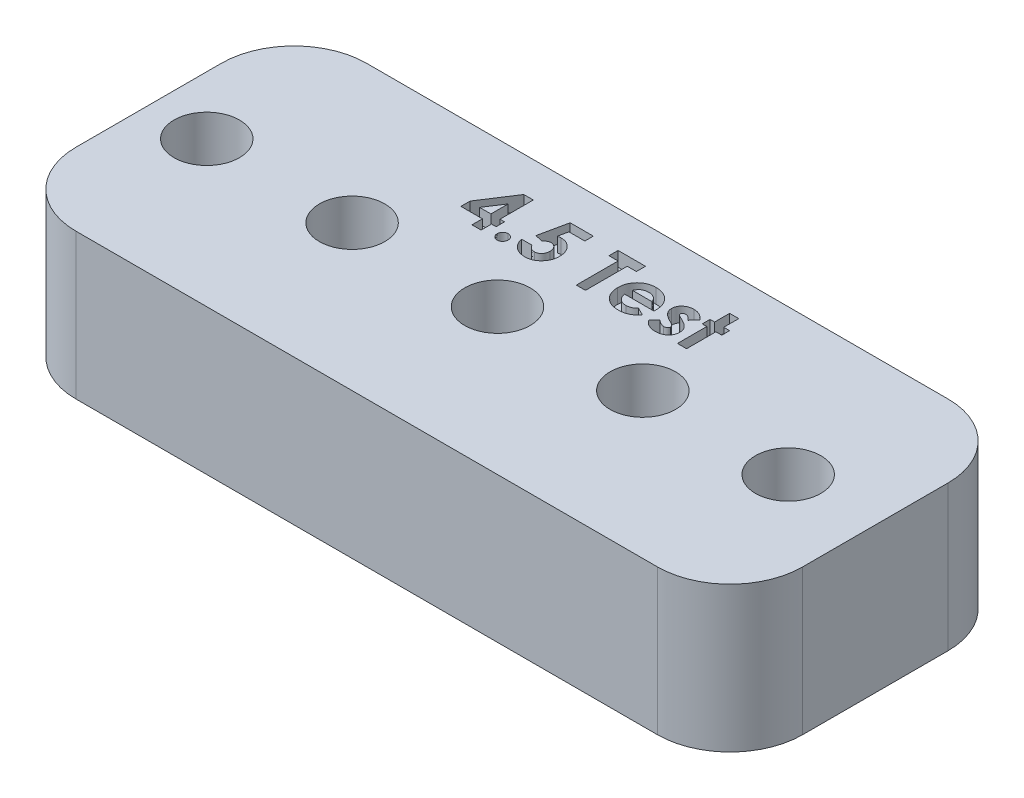
from build123d import *

# Parameters (mm, degrees)
SKETCH1_W                      = 100
SKETCH1_H                      = 20
BOSS_EXTRUDE1_DEPTH            = 10
M4_CLEARANCE_HOLE1_D           = 4.5
M4_CLEARANCE_HOLE1_DEPTH       = 5
M4_CLEARANCE_HOLE1_TIP         = 1.351936393
M4_CLEARANCE_HOLE2_D           = 4.5
M4_CLEARANCE_HOLE2_DEPTH       = 5
M4_CLEARANCE_HOLE2_TIP         = 1.351936393
CUT_EXTRUDE1_DEPTH             = 1
M4_CLEARANCE_HOLE3_D           = 4.5
M4_CLEARANCE_HOLE3_DEPTH       = 5
M4_CLEARANCE_HOLE3_TIP         = 1.351936393
F_5_0_5_DIAMETER_HOLE1_D       = 5
F_5_0_5_DIAMETER_HOLE1_DEPTH   = 5
F_5_0_5_DIAMETER_HOLE1_TIP     = 1.502151548
F_5_1_5_1_DIAMETER_HOLE1_D     = 5.1
F_5_1_5_1_DIAMETER_HOLE1_DEPTH = 5
F_5_1_5_1_DIAMETER_HOLE1_TIP   = 1.532194579
F_5_2_5_2_DIAMETER_HOLE1_D     = 5.2
F_5_2_5_2_DIAMETER_HOLE1_DEPTH = 5
F_5_2_5_2_DIAMETER_HOLE1_TIP   = 1.562237609
CUT_EXTRUDE2_DEPTH             = 1
FILLET1_R                      = 5
SKETCH33_W                     = 50
SKETCH33_H                     = 21.030948993
CUT_EXTRUDE4_DEPTH             = 52.961524362
FILLET2_R                      = 5


with BuildPart() as part:
    # Sketch1 → Boss-Extrude1 (new body)
    with BuildSketch(Plane(origin=(0, 0, 0), x_dir=(1, 0, 0), z_dir=(0, 1, 0))):
        Rectangle(SKETCH1_W, SKETCH1_H)
    extrude(amount=BOSS_EXTRUDE1_DEPTH)

    # M4 Clearance Hole1
    with Locations(Plane(origin=(0, 10, 0), x_dir=(1, 0, 0), z_dir=(0, 1, 0))):
        with Locations((-6, 0), (-16, 0)):
            Hole(M4_CLEARANCE_HOLE1_D / 2, depth=M4_CLEARANCE_HOLE1_DEPTH)
            with Locations((0, 0, -(M4_CLEARANCE_HOLE1_DEPTH + M4_CLEARANCE_HOLE1_TIP / 2))):  # 118° drill point
                Cone(0, M4_CLEARANCE_HOLE1_D / 2, M4_CLEARANCE_HOLE1_TIP, mode=Mode.SUBTRACT)

    # M4 Clearance Hole2
    with Locations(Plane(origin=(0, 10, 0), x_dir=(1, 0, 0), z_dir=(0, 1, 0))):
        with Locations((-26, 0), (-36, 0)):
            Hole(M4_CLEARANCE_HOLE2_D / 2, depth=M4_CLEARANCE_HOLE2_DEPTH)
            with Locations((0, 0, -(M4_CLEARANCE_HOLE2_DEPTH + M4_CLEARANCE_HOLE2_TIP / 2))):  # 118° drill point
                Cone(0, M4_CLEARANCE_HOLE2_D / 2, M4_CLEARANCE_HOLE2_TIP, mode=Mode.SUBTRACT)

    # Sketch9 → Cut-Extrude1 (cut)
    with BuildSketch(Plane(origin=(0, 10, 0), x_dir=(1, 0, 0), z_dir=(0, 1, 0))):
        Polygon((-31.779847756, 7.58974359), (-31.125, 7.58974359), (-31.125, 5.301282051), (-30.810897436, 5.301282051), (-30.810897436, 4.717948718), (-31.125, 4.717948718), (-31.125, 4), (-31.753205128, 4), (-31.753205128, 4.717948718), (-33.233974359, 4.717948718), (-33.233974359, 5.353866186), align=None)
        Polygon((-31.753205128, 5.301282051), (-31.753205128, 6.492487981), (-32.527944712, 5.301282051), align=None, mode=Mode.SUBTRACT)
        with BuildLine():
            add(Edge.make_bspline(
                [(-29.980769231, 4.717948718), (-29.955409335, 4.716558296), (-29.905480079, 4.713820795), (-29.833339112, 4.69339111), (-29.768231474, 4.656686271), (-29.710016547, 4.608811171), (-29.66079147, 4.551211032), (-29.625212697, 4.485525117), (-29.603056903, 4.41366212), (-29.600610888, 4.36357578), (-29.599358974, 4.337940705)],
                knots=[0, 0, 0, 0, 1.016957001, 2.002212695, 2.9757545, 3.99499976, 5.013036768, 5.994806404, 6.97370641, 8, 8, 8, 8], degree=3))
            add(Edge.make_bspline(
                [(-29.599358974, 4.337940705), (-29.600602687, 4.312301513), (-29.603032678, 4.262207129), (-29.625366013, 4.190204101), (-29.660738304, 4.123978308), (-29.710020496, 4.065760947), (-29.767990386, 4.016983595), (-29.833488806, 3.980617228), (-29.905342652, 3.95902862), (-29.955385146, 3.956440852), (-29.980769231, 3.955128205)],
                knots=[0, 0, 0, 0, 1.023218912, 1.999186227, 2.986238111, 4.008388923, 5.030539734, 6.0011649, 6.986089706, 8, 8, 8, 8], degree=3))
            add(Edge.make_bspline(
                [(-29.980769231, 3.955128205), (-30.00615933, 3.956430178), (-30.056213682, 3.958996903), (-30.12817922, 3.980799199), (-30.1941612, 4.016740799), (-30.252145655, 4.065820114), (-30.301648018, 4.123772156), (-30.336014642, 4.190413056), (-30.358556005, 4.262179983), (-30.360952777, 4.312292323), (-30.362179487, 4.337940705)],
                knots=[0, 0, 0, 0, 1.013427518, 1.99788335, 2.976245624, 3.997909735, 5.019573847, 6.001765691, 6.977268297, 8, 8, 8, 8], degree=3))
            add(Edge.make_bspline(
                [(-30.362179487, 4.337940705), (-30.360944684, 4.363585131), (-30.3585321, 4.413689738), (-30.336167521, 4.485313756), (-30.30159294, 4.551418305), (-30.252149783, 4.608751881), (-30.19391887, 4.656927172), (-30.128329753, 4.693211633), (-30.056076324, 4.713852746), (-30.00613517, 4.716569058), (-29.980769231, 4.717948718)],
                knots=[0, 0, 0, 0, 1.025808215, 2.00424526, 2.981110158, 3.998665696, 5.017428914, 5.998734231, 6.983523959, 8, 8, 8, 8], degree=3))
        make_face()
        with BuildLine():
            Line((-28.500701122, 7.5), (-26.907051282, 7.5))
            Line((-26.907051282, 7.5), (-26.907051282, 6.916666667))
            Line((-26.907051282, 6.916666667), (-28.002904647, 6.916666667))
            Line((-28.002904647, 6.916666667), (-28.139623397, 6.254807692))
            add(Edge.make_bspline(
                [(-28.139623397, 6.254807692), (-28.120993511, 6.259996351), (-28.084251546, 6.270229452), (-28.028899731, 6.280491957), (-27.975256109, 6.287143787), (-27.940055491, 6.288031053), (-27.922976763, 6.288461538)],
                knots=[0, 0, 0, 0, 1.05461699, 2.079921384, 3.068411212, 4, 4, 4, 4], degree=3))
            add(Edge.make_bspline(
                [(-27.922976763, 6.288461538), (-27.885760425, 6.287608748), (-27.812398825, 6.285927709), (-27.705080113, 6.26996917), (-27.602316106, 6.244834954), (-27.504421274, 6.208988378), (-27.411491247, 6.162333132), (-27.323413376, 6.105893363), (-27.240079559, 6.039569942), (-27.162970155, 5.963321345), (-27.092118815, 5.879598659), (-27.030517615, 5.789043716), (-26.977906346, 5.69294774), (-26.936061162, 5.590713401), (-26.903033375, 5.4829828), (-26.879166759, 5.3696869), (-26.865053236, 5.250691427), (-26.863150114, 5.169509324), (-26.862179487, 5.128104968)],
                knots=[0, 0, 0, 0, 1.01440847, 1.999622559, 2.951875003, 3.895578053, 4.836219714, 5.782137149, 6.743708247, 7.735272588, 8.734977101, 9.730283169, 10.717124674, 11.717316708, 12.737475749, 13.78628267, 14.87096371, 16, 16, 16, 16], degree=3))
            add(Edge.make_bspline(
                [(-26.862179487, 5.128104968), (-26.863365609, 5.086230577), (-26.865706174, 5.003600162), (-26.880976216, 4.882104224), (-26.907928114, 4.765738544), (-26.944949243, 4.654191613), (-26.99372221, 4.548283274), (-27.052378378, 4.446916397), (-27.121909465, 4.350843395), (-27.201633132, 4.261049133), (-27.288303217, 4.178975454), (-27.380586397, 4.106775081), (-27.477834357, 4.046019052), (-27.580049442, 3.996917909), (-27.686645213, 3.958069959), (-27.797654022, 3.929790505), (-27.913615358, 3.91357381), (-27.992338037, 3.911374362), (-28.032351763, 3.91025641)],
                knots=[0, 0, 0, 0, 1.06808661, 2.107647099, 3.116961351, 4.110378221, 5.100014249, 6.085620622, 7.093190682, 8.119403071, 9.144090782, 10.133780668, 11.103064255, 12.062861538, 13.020824475, 13.992378307, 14.979551724, 16, 16, 16, 16], degree=3))
            add(Edge.make_bspline(
                [(-28.032351763, 3.91025641), (-28.068134846, 3.911170964), (-28.138706575, 3.912974655), (-28.242655634, 3.924061093), (-28.34287407, 3.943662018), (-28.438829833, 3.972029632), (-28.531532538, 4.006943689), (-28.619910514, 4.050610316), (-28.704449415, 4.10219804), (-28.784909182, 4.160765386), (-28.859982458, 4.226739229), (-28.928501389, 4.298958967), (-28.990880798, 4.376514305), (-29.045785863, 4.460362042), (-29.093044473, 4.550378295), (-29.134954373, 4.645502204), (-29.169258045, 4.746727166), (-29.186666171, 4.816901933), (-29.195512821, 4.852564103)],
                knots=[0, 0, 0, 0, 1.054957082, 2.080596141, 3.077793124, 4.061112343, 5.027190972, 5.994718051, 6.962465889, 7.943658696, 8.924948258, 9.904494768, 10.875059, 11.855380583, 12.854004648, 13.869083016, 14.917087635, 16, 16, 16, 16], degree=3))
            Line((-29.195512821, 4.852564103), (-28.477564103, 4.852564103))
            add(Edge.make_bspline(
                [(-28.477564103, 4.852564103), (-28.464439983, 4.827851671), (-28.438934753, 4.779825881), (-28.390418169, 4.716064428), (-28.336106932, 4.661691401), (-28.276490961, 4.616175562), (-28.21118398, 4.58207587), (-28.142847127, 4.556216242), (-28.070621913, 4.54127292), (-28.021433353, 4.539404857), (-27.996594551, 4.538461538)],
                knots=[0, 0, 0, 0, 1.104910296, 2.147267069, 3.153527244, 4.136738762, 5.099945312, 6.05603338, 7.018353, 8, 8, 8, 8], degree=3))
            add(Edge.make_bspline(
                [(-27.996594551, 4.538461538), (-27.97928224, 4.539112908), (-27.945219975, 4.540394488), (-27.895034613, 4.547174369), (-27.847130481, 4.560015309), (-27.801151422, 4.577797026), (-27.756973925, 4.599972835), (-27.71523129, 4.62796835), (-27.67519727, 4.660192225), (-27.637481345, 4.697169231), (-27.603321587, 4.738389992), (-27.573367217, 4.782684509), (-27.546583879, 4.829068549), (-27.526745051, 4.879379501), (-27.510498729, 4.932115061), (-27.49853428, 4.98767303), (-27.491384172, 5.046118294), (-27.490722263, 5.086017238), (-27.490384615, 5.106370192)],
                knots=[0, 0, 0, 0, 0.978869489, 1.925942215, 2.855067702, 3.774946051, 4.70828698, 5.642468714, 6.60995405, 7.609372294, 8.622401667, 9.629904756, 10.629323, 11.642352373, 12.678539694, 13.745912462, 14.850161547, 16, 16, 16, 16], degree=3))
            add(Edge.make_bspline(
                [(-27.490384615, 5.106370192), (-27.490776495, 5.126250708), (-27.491539298, 5.164948615), (-27.497849357, 5.221771003), (-27.50913793, 5.275685166), (-27.524518709, 5.327104046), (-27.544207941, 5.375715402), (-27.5682695, 5.421808594), (-27.596806177, 5.465150636), (-27.629971182, 5.504859127), (-27.665338001, 5.541280884), (-27.703333329, 5.573135063), (-27.743614849, 5.59957182), (-27.784930861, 5.622651878), (-27.828930552, 5.639449041), (-27.874624547, 5.651016627), (-27.921964791, 5.659504457), (-27.954254544, 5.660003148), (-27.970653045, 5.66025641)],
                knots=[0, 0, 0, 0, 1.166249705, 2.270133367, 3.348514167, 4.393962215, 5.415026464, 6.420877785, 7.440098956, 8.453121383, 9.451844239, 10.415694839, 11.355045125, 12.27538808, 13.187007209, 14.108269027, 15.039275622, 16, 16, 16, 16], degree=3))
            add(Edge.make_bspline(
                [(-27.970653045, 5.66025641), (-27.988465629, 5.659580522), (-28.024165868, 5.658225896), (-28.077207488, 5.647203668), (-28.129609573, 5.629365569), (-28.181663534, 5.604755084), (-28.232852644, 5.572547724), (-28.284527808, 5.534772184), (-28.33495935, 5.488683712), (-28.367025126, 5.454356913), (-28.383613782, 5.436598558)],
                knots=[0, 0, 0, 0, 0.88288272, 1.769486374, 2.674910571, 3.623812639, 4.617874466, 5.670434592, 6.794841017, 8, 8, 8, 8], degree=3))
            Line((-28.383613782, 5.436598558), (-28.912259615, 5.557892628))
            Line((-28.912259615, 5.557892628), (-28.500701122, 7.5))
        make_face()
        Polygon((-25.201923077, 7.5), (-23.317307692, 7.5), (-23.317307692, 6.871794872), (-23.945512821, 6.871794872), (-23.945512821, 4), (-24.573717949, 4), (-24.573717949, 6.871794872), (-25.201923077, 6.871794872), align=None)
        with BuildLine():
            Line((-20.357872596, 5.121794872), (-22.375, 5.121794872))
            add(Edge.make_bspline(
                [(-22.375, 5.121794872), (-22.37088724, 5.098356996), (-22.362805342, 5.05229972), (-22.345255214, 4.985397531), (-22.322858619, 4.922350037), (-22.296017709, 4.863072959), (-22.265185024, 4.807252923), (-22.22922125, 4.755151746), (-22.188582557, 4.706815448), (-22.143503905, 4.662454103), (-22.094736675, 4.622705377), (-22.042517369, 4.58788298), (-21.986792101, 4.559330745), (-21.928199739, 4.535264173), (-21.866302464, 4.51620101), (-21.801009178, 4.503053509), (-21.732492965, 4.495287233), (-21.685817627, 4.494163929), (-21.661959135, 4.493589744)],
                knots=[0, 0, 0, 0, 1.091296461, 2.144483647, 3.168565212, 4.157007626, 5.126487748, 6.090021542, 7.05641414, 8.019231907, 8.98705074, 9.938580405, 10.892824166, 11.854447369, 12.841318655, 13.858982407, 14.905600794, 16, 16, 16, 16], degree=3))
            add(Edge.make_bspline(
                [(-21.661959135, 4.493589744), (-21.633160314, 4.49435006), (-21.576446956, 4.495847348), (-21.493361464, 4.509126063), (-21.413005691, 4.52918298), (-21.336140084, 4.559009298), (-21.261874277, 4.596137822), (-21.191430914, 4.642395393), (-21.123590673, 4.696430216), (-21.082200132, 4.738080236), (-21.061097756, 4.759314904)],
                knots=[0, 0, 0, 0, 1.021034703, 2.010718019, 2.977989445, 3.954245119, 4.929443971, 5.918328161, 6.938689359, 8, 8, 8, 8], degree=3))
            Line((-21.061097756, 4.759314904), (-20.53525641, 4.509014423))
            add(Edge.make_bspline(
                [(-20.53525641, 4.509014423), (-20.551812218, 4.486136838), (-20.584616943, 4.440805743), (-20.638169554, 4.377013186), (-20.694055115, 4.317492141), (-20.752315303, 4.26263409), (-20.813024008, 4.212595354), (-20.876012353, 4.166766372), (-20.942200886, 4.126377634), (-21.010266179, 4.089475157), (-21.081615269, 4.057838835), (-21.156050701, 4.030860496), (-21.233257199, 4.006472307), (-21.314209714, 3.987889843), (-21.398234155, 3.973180116), (-21.485531526, 3.962734261), (-21.57609032, 3.956282357), (-21.637642605, 3.955517492), (-21.668970353, 3.955128205)],
                knots=[0, 0, 0, 0, 1.028154879, 2.037251081, 3.030720504, 4.000128189, 4.949298328, 5.894184978, 6.834267904, 7.770992897, 8.712077017, 9.673380525, 10.653304757, 11.658697181, 12.695551717, 13.758623199, 14.859225354, 16, 16, 16, 16], degree=3))
            add(Edge.make_bspline(
                [(-21.668970353, 3.955128205), (-21.717167577, 3.956110802), (-21.811559065, 3.95803516), (-21.949623678, 3.97589596), (-22.080746767, 4.005511093), (-22.205298578, 4.045768317), (-22.322740714, 4.098920464), (-22.433131298, 4.163929949), (-22.53757329, 4.23955041), (-22.632875404, 4.32736892), (-22.719698442, 4.422954147), (-22.7959584, 4.525606153), (-22.859771647, 4.634607748), (-22.912176369, 4.749237537), (-22.952907139, 4.869788926), (-22.982271662, 4.996314522), (-23.000272466, 5.128753894), (-23.002216642, 5.218959891), (-23.003205128, 5.264823718)],
                knots=[0, 0, 0, 0, 1.103565453, 2.161269334, 3.182010356, 4.179077853, 5.15417608, 6.128274628, 7.109042802, 8.101804412, 9.090965879, 10.063106201, 11.02526161, 11.978650795, 12.945248442, 13.93468508, 14.949922959, 16, 16, 16, 16], degree=3))
            add(Edge.make_bspline(
                [(-23.003205128, 5.264823718), (-23.002206913, 5.311853003), (-23.000242971, 5.404381011), (-22.982426648, 5.539878469), (-22.952825956, 5.669161371), (-22.911976039, 5.792407752), (-22.860366304, 5.910003076), (-22.795741143, 6.020918523), (-22.719736286, 6.125540241), (-22.633226026, 6.223378799), (-22.537520183, 6.311688786), (-22.435823682, 6.390390633), (-22.32699386, 6.455970236), (-22.212261675, 6.508958515), (-22.092360996, 6.552010153), (-21.965905939, 6.580657423), (-21.833858633, 6.59989235), (-21.743594002, 6.601663767), (-21.697716346, 6.602564103)],
                knots=[0, 0, 0, 0, 1.079208495, 2.12329425, 3.130605359, 4.119693003, 5.099659317, 6.073216462, 7.060498243, 8.06384408, 9.066070512, 10.045757761, 11.010926815, 11.975797609, 12.942977511, 13.929384301, 14.947594487, 16, 16, 16, 16], degree=3))
            add(Edge.make_bspline(
                [(-21.697716346, 6.602564103), (-21.649288224, 6.601566262), (-21.554204597, 6.599607105), (-21.415178406, 6.58189133), (-21.283184675, 6.552095608), (-21.157661038, 6.512186481), (-21.040210482, 6.457691654), (-20.928252262, 6.39428195), (-20.824471772, 6.317026895), (-20.727762823, 6.229638141), (-20.640463231, 6.132683347), (-20.564153715, 6.027360745), (-20.499223708, 5.914698223), (-20.446597294, 5.79423891), (-20.405908347, 5.666344436), (-20.376516642, 5.531180898), (-20.35865314, 5.388234198), (-20.356745141, 5.290350399), (-20.355769231, 5.240284455)],
                knots=[0, 0, 0, 0, 1.080001299, 2.120471247, 3.119684163, 4.095710327, 5.052285597, 6.002875087, 6.961153713, 7.931888285, 8.906493152, 9.865905668, 10.82813294, 11.801621613, 12.7925306, 13.817193356, 14.883530496, 16, 16, 16, 16], degree=3))
            Line((-20.355769231, 5.240284455), (-20.357872596, 5.121794872))
        make_face()
        with BuildLine():
            add(Edge.make_bspline(
                [(-20.983974359, 5.615384615), (-20.995828974, 5.647375419), (-21.019399037, 5.710981471), (-21.072642827, 5.798742302), (-21.143295634, 5.874746746), (-21.225469917, 5.942034083), (-21.319359181, 5.996648688), (-21.42200481, 6.036191437), (-21.532109384, 6.059901765), (-21.607855398, 6.06268257), (-21.646534455, 6.064102564)],
                knots=[0, 0, 0, 0, 0.954238005, 1.897273737, 2.851915805, 3.847685534, 4.862635127, 5.880135777, 6.917509367, 8, 8, 8, 8], degree=3))
            add(Edge.make_bspline(
                [(-21.646534455, 6.064102564), (-21.688778284, 6.062738487), (-21.771356172, 6.060071999), (-21.890469154, 6.031712926), (-22.002825449, 5.989387857), (-22.069064352, 5.945749811), (-22.102263622, 5.923878205)],
                knots=[0, 0, 0, 0, 1.044195649, 2.041185066, 3.018232172, 4, 4, 4, 4], degree=3))
            add(Edge.make_bspline(
                [(-22.102263622, 5.923878205), (-22.122977486, 5.907220311), (-22.167138387, 5.871706531), (-22.224490275, 5.800859913), (-22.280982362, 5.715080563), (-22.313101229, 5.649925086), (-22.330128205, 5.615384615)],
                knots=[0, 0, 0, 0, 0.82159062, 1.751589201, 2.808063854, 4, 4, 4, 4], degree=3))
            Line((-22.330128205, 5.615384615), (-20.983974359, 5.615384615))
        make_face(mode=Mode.SUBTRACT)
        with BuildLine():
            Line((-18.246794872, 6.162960737), (-18.631009615, 5.75))
            add(Edge.make_bspline(
                [(-18.631009615, 5.75), (-18.650195298, 5.771229998), (-18.686890242, 5.811834943), (-18.743066654, 5.867188557), (-18.798406489, 5.913281766), (-18.851878495, 5.952001983), (-18.90457476, 5.981695761), (-18.956057261, 6.003059769), (-19.006350697, 6.016621959), (-19.039687313, 6.018377533), (-19.055889423, 6.019230769)],
                knots=[0, 0, 0, 0, 1.327646587, 2.539285, 3.655602211, 4.666613517, 5.598770349, 6.454635452, 7.248928967, 8, 8, 8, 8], degree=3))
            add(Edge.make_bspline(
                [(-19.055889423, 6.019230769), (-19.072284331, 6.018731109), (-19.10367548, 6.017774414), (-19.147975424, 6.009568373), (-19.186895889, 5.995362204), (-19.219829496, 5.975997872), (-19.246288939, 5.952143003), (-19.264814428, 5.924853596), (-19.277254465, 5.894978416), (-19.278306812, 5.873756921), (-19.278846154, 5.862880609)],
                knots=[0, 0, 0, 0, 1.295068245, 2.479652818, 3.543291146, 4.55379989, 5.481948265, 6.332409746, 7.145336708, 8, 8, 8, 8], degree=3))
            add(Edge.make_bspline(
                [(-19.278846154, 5.862880609), (-19.277018813, 5.846398295), (-19.273227292, 5.812199408), (-19.247184803, 5.772533801), (-19.21272871, 5.743273295), (-19.173010797, 5.716044713), (-19.119222461, 5.685600244), (-19.078417263, 5.664754027), (-19.055889423, 5.653245192)],
                knots=[0, 0, 0, 0, 0.916701701, 1.902049539, 2.5493345, 3.440293453, 4.586830489, 6, 6, 6, 6], degree=3))
            Line((-19.055889423, 5.653245192), (-18.828725962, 5.538261218))
            add(Edge.make_bspline(
                [(-18.828725962, 5.538261218), (-18.799826426, 5.523586972), (-18.743755898, 5.49511618), (-18.664925988, 5.449174733), (-18.592117427, 5.404644983), (-18.526790732, 5.359008004), (-18.468546063, 5.313056663), (-18.417797129, 5.266336561), (-18.373313011, 5.220328815), (-18.323706976, 5.158645006), (-18.274086053, 5.076487191), (-18.232717615, 4.969644781), (-18.206337464, 4.855240051), (-18.203418804, 4.776056176), (-18.201923077, 4.735476763)],
                knots=[0, 0, 0, 0, 1.076693506, 2.088987655, 3.030641824, 3.911722491, 4.735175175, 5.493635918, 6.202154166, 6.859459289, 8.120623445, 9.372284821, 10.653373066, 12, 12, 12, 12], degree=3))
            add(Edge.make_bspline(
                [(-18.201923077, 4.735476763), (-18.202824262, 4.708100165), (-18.204588121, 4.654516899), (-18.215738866, 4.575647439), (-18.235768491, 4.50065426), (-18.262127446, 4.428368367), (-18.29763217, 4.360096911), (-18.340736644, 4.295508935), (-18.390760233, 4.233756435), (-18.449025382, 4.17695184), (-18.512853879, 4.124010581), (-18.583810025, 4.079483179), (-18.658756447, 4.040333359), (-18.739673112, 4.009760836), (-18.825424658, 3.984974642), (-18.916746152, 3.967798431), (-19.013327723, 3.956989001), (-19.079463864, 3.955759003), (-19.11338141, 3.955128205)],
                knots=[0, 0, 0, 0, 0.976600749, 1.911466839, 2.833459288, 3.740827163, 4.650527853, 5.570709661, 6.506801416, 7.479409329, 8.468875524, 9.458587492, 10.461481786, 11.480119772, 12.538142914, 13.641687514, 14.790552763, 16, 16, 16, 16], degree=3))
            add(Edge.make_bspline(
                [(-19.11338141, 3.955128205), (-19.158319246, 3.956559226), (-19.246528262, 3.959368193), (-19.375351143, 3.978935056), (-19.496994143, 4.012805626), (-19.61155734, 4.060253962), (-19.719742417, 4.120716149), (-19.820004371, 4.195736488), (-19.914081334, 4.283360382), (-19.968816289, 4.350563828), (-19.996794872, 4.384915865)],
                knots=[0, 0, 0, 0, 1.056901255, 2.07460411, 3.05625841, 4.019970729, 4.984811261, 5.963335951, 6.958928997, 8, 8, 8, 8], degree=3))
            Line((-19.996794872, 4.384915865), (-19.616085737, 4.807692308))
            add(Edge.make_bspline(
                [(-19.616085737, 4.807692308), (-19.597536302, 4.788127424), (-19.560709608, 4.749284732), (-19.498634683, 4.69806539), (-19.432955015, 4.651382728), (-19.362939434, 4.612184524), (-19.292909706, 4.580533738), (-19.225721959, 4.556791221), (-19.162642422, 4.541870652), (-19.121629733, 4.539558825), (-19.102163462, 4.538461538)],
                knots=[0, 0, 0, 0, 1.087861918, 2.159761696, 3.243809206, 4.338405912, 5.394481878, 6.343674753, 7.213841449, 8, 8, 8, 8], degree=3))
            add(Edge.make_bspline(
                [(-19.102163462, 4.538461538), (-19.082707727, 4.53902499), (-19.045308437, 4.540108098), (-18.992154361, 4.551374552), (-18.945041454, 4.570315126), (-18.905087954, 4.596576712), (-18.871855703, 4.626721002), (-18.848439953, 4.660980164), (-18.832956219, 4.697307916), (-18.831074353, 4.722706898), (-18.830128205, 4.735476763)],
                knots=[0, 0, 0, 0, 1.255011871, 2.412479185, 3.488767498, 4.514443302, 5.48617286, 6.365347346, 7.178144445, 8, 8, 8, 8], degree=3))
            add(Edge.make_bspline(
                [(-18.830128205, 4.735476763), (-18.830972449, 4.747502279), (-18.832705845, 4.772192983), (-18.846429196, 4.808638228), (-18.867975127, 4.844724868), (-18.897858158, 4.880554648), (-18.936475921, 4.915836852), (-18.983690212, 4.950288881), (-19.038411796, 4.985748793), (-19.078832272, 5.006913612), (-19.100060096, 5.018028846)],
                knots=[0, 0, 0, 0, 0.704666567, 1.446816302, 2.258757648, 3.165368109, 4.175243826, 5.322435858, 6.59381024, 8, 8, 8, 8], degree=3))
            Line((-19.100060096, 5.018028846), (-19.308293269, 5.123197115))
            add(Edge.make_bspline(
                [(-19.308293269, 5.123197115), (-19.355528865, 5.148526732), (-19.4462035, 5.197150098), (-19.56876171, 5.280528839), (-19.672489541, 5.369287167), (-19.757471524, 5.462948244), (-19.825185336, 5.561249233), (-19.872420263, 5.665441698), (-19.902135347, 5.774537872), (-19.905404482, 5.84913902), (-19.907051282, 5.88671875)],
                knots=[0, 0, 0, 0, 1.255999728, 2.41104856, 3.467751088, 4.449286722, 5.368722015, 6.253902015, 7.120417131, 8, 8, 8, 8], degree=3))
            add(Edge.make_bspline(
                [(-19.907051282, 5.88671875), (-19.906480185, 5.911074399), (-19.90535903, 5.958888495), (-19.893423656, 6.029106809), (-19.875391867, 6.096604459), (-19.84994707, 6.161488639), (-19.81735273, 6.223823729), (-19.777419008, 6.283333092), (-19.729658718, 6.33990854), (-19.675600866, 6.393367831), (-19.615621983, 6.442055509), (-19.551435757, 6.485204177), (-19.483232038, 6.521958818), (-19.410451088, 6.551262233), (-19.334017992, 6.574585927), (-19.253428211, 6.590439711), (-19.169025577, 6.600522773), (-19.111307636, 6.601874018), (-19.081830929, 6.602564103)],
                knots=[0, 0, 0, 0, 0.959035663, 1.882742823, 2.798841253, 3.708806893, 4.623422363, 5.566085165, 6.527241613, 7.536786942, 8.55815439, 9.567237405, 10.580975912, 11.605536372, 12.654523293, 13.725718749, 14.838518481, 16, 16, 16, 16], degree=3))
            add(Edge.make_bspline(
                [(-19.081830929, 6.602564103), (-19.041079192, 6.601222387), (-18.960194181, 6.598559319), (-18.840904699, 6.577009755), (-18.725683432, 6.540789912), (-18.614853401, 6.490885025), (-18.509840224, 6.428168766), (-18.412953194, 6.352010045), (-18.323536612, 6.264284235), (-18.272629472, 6.197070624), (-18.246794872, 6.162960737)],
                knots=[0, 0, 0, 0, 0.996590028, 1.978055413, 2.954661574, 3.945146934, 4.945404762, 5.939399542, 6.954276554, 8, 8, 8, 8], degree=3))
        make_face()
        Polygon((-17.618589744, 7.58974359), (-16.990384615, 7.58974359), (-16.990384615, 6.557692308), (-16.586538462, 6.557692308), (-16.586538462, 6.019230769), (-16.990384615, 6.019230769), (-16.990384615, 4), (-17.618589744, 4), (-17.618589744, 6.019230769), (-17.932692308, 6.019230769), (-17.932692308, 6.557692308), (-17.618589744, 6.557692308), align=None)
    extrude(amount=-CUT_EXTRUDE1_DEPTH, mode=Mode.SUBTRACT)

    # M4 Clearance Hole3
    with Locations(Plane(origin=(0, 10, 0), x_dir=(1, 0, 0), z_dir=(0, 1, 0))):
        with Locations((-46, 0)):
            Hole(M4_CLEARANCE_HOLE3_D / 2, depth=M4_CLEARANCE_HOLE3_DEPTH)
            with Locations((0, 0, -(M4_CLEARANCE_HOLE3_DEPTH + M4_CLEARANCE_HOLE3_TIP / 2))):  # 118° drill point
                Cone(0, M4_CLEARANCE_HOLE3_D / 2, M4_CLEARANCE_HOLE3_TIP, mode=Mode.SUBTRACT)

    # Ø5.0 (5) Diameter Hole1
    with Locations(Plane(origin=(0, 10, 0), x_dir=(1, 0, 0), z_dir=(0, 1, 0))):
        with Locations((6, 0), (16, 0)):
            Hole(F_5_0_5_DIAMETER_HOLE1_D / 2, depth=F_5_0_5_DIAMETER_HOLE1_DEPTH)
            with Locations((0, 0, -(F_5_0_5_DIAMETER_HOLE1_DEPTH + F_5_0_5_DIAMETER_HOLE1_TIP / 2))):  # 118° drill point
                Cone(0, F_5_0_5_DIAMETER_HOLE1_D / 2, F_5_0_5_DIAMETER_HOLE1_TIP, mode=Mode.SUBTRACT)

    # Ø5.1 (5.1) Diameter Hole1
    with Locations(Plane(origin=(0, 10, 0), x_dir=(1, 0, 0), z_dir=(0, 1, 0))):
        with Locations((26, 0), (36, 0)):
            Hole(F_5_1_5_1_DIAMETER_HOLE1_D / 2, depth=F_5_1_5_1_DIAMETER_HOLE1_DEPTH)
            with Locations((0, 0, -(F_5_1_5_1_DIAMETER_HOLE1_DEPTH + F_5_1_5_1_DIAMETER_HOLE1_TIP / 2))):  # 118° drill point
                Cone(0, F_5_1_5_1_DIAMETER_HOLE1_D / 2, F_5_1_5_1_DIAMETER_HOLE1_TIP, mode=Mode.SUBTRACT)

    # Ø5.2 (5.2) Diameter Hole1
    with Locations(Plane(origin=(0, 10, 0), x_dir=(1, 0, 0), z_dir=(0, 1, 0))):
        with Locations((46, 0)):
            Hole(F_5_2_5_2_DIAMETER_HOLE1_D / 2, depth=F_5_2_5_2_DIAMETER_HOLE1_DEPTH)
            with Locations((0, 0, -(F_5_2_5_2_DIAMETER_HOLE1_DEPTH + F_5_2_5_2_DIAMETER_HOLE1_TIP / 2))):  # 118° drill point
                Cone(0, F_5_2_5_2_DIAMETER_HOLE1_D / 2, F_5_2_5_2_DIAMETER_HOLE1_TIP, mode=Mode.SUBTRACT)

    # Sketch24 → Cut-Extrude2 (cut)
    with BuildSketch(Plane(origin=(0, 10, 0), x_dir=(1, 0, 0), z_dir=(0, 1, 0))):
        Polygon((15.651943109, 7.5), (16.303986378, 7.5), (17.102564103, 5.05869391), (17.906750801, 7.5), (18.552483974, 7.5), (19.144230769, 4), (18.508313301, 4), (18.134615385, 6.210637019), (17.406850962, 4), (16.794070513, 4), (16.070512821, 6.210637019), (15.697516026, 4), (15.060897436, 4), align=None)
        with BuildLine():
            Line((20.266025641, 6.647435897), (19.637820513, 6.647435897))
            add(Edge.make_bspline(
                [(19.637820513, 6.647435897), (19.64225588, 6.678837631), (19.650951123, 6.740398649), (19.671757678, 6.829523667), (19.696644563, 6.914064846), (19.727714567, 6.993754462), (19.764154627, 7.068734468), (19.805594188, 7.139262159), (19.852481228, 7.205034816), (19.88842064, 7.244656526), (19.90635016, 7.264423077)],
                knots=[0, 0, 0, 0, 1.111473889, 2.178970933, 3.205615836, 4.199322666, 5.174200091, 6.12565194, 7.064921805, 8, 8, 8, 8], degree=3))
            add(Edge.make_bspline(
                [(19.90635016, 7.264423077), (19.932211117, 7.290503609), (19.983180345, 7.341905597), (20.068355903, 7.407745865), (20.157635618, 7.46472614), (20.252810034, 7.509900514), (20.352398164, 7.546463936), (20.457191969, 7.571023669), (20.566763222, 7.587319269), (20.641531818, 7.588924443), (20.6796875, 7.58974359)],
                knots=[0, 0, 0, 0, 1.01925491, 2.00884431, 2.983262333, 3.955970413, 4.92937149, 5.924503185, 6.940838805, 8, 8, 8, 8], degree=3))
            add(Edge.make_bspline(
                [(20.6796875, 7.58974359), (20.713609864, 7.588942749), (20.780294397, 7.587368458), (20.87830388, 7.574730903), (20.971747721, 7.552566039), (21.061613647, 7.523585976), (21.146580024, 7.484153758), (21.228522142, 7.438381345), (21.305150535, 7.382239579), (21.376644499, 7.318805033), (21.442325341, 7.250194362), (21.499205238, 7.176855197), (21.548105906, 7.100746596), (21.588393588, 7.021236241), (21.619369341, 6.93818959), (21.640867432, 6.852086394), (21.654938455, 6.763116644), (21.656340296, 6.702645104), (21.657051282, 6.67197516)],
                knots=[0, 0, 0, 0, 1.091422571, 2.145516843, 3.172569842, 4.178562979, 5.178154469, 6.181868002, 7.194278174, 8.227918432, 9.254613415, 10.245994977, 11.209837596, 12.161663635, 13.10878368, 14.055455738, 15.013766427, 16, 16, 16, 16], degree=3))
            add(Edge.make_bspline(
                [(21.657051282, 6.67197516), (21.655592297, 6.633992989), (21.652720004, 6.559217771), (21.629150758, 6.449778683), (21.59225848, 6.345135386), (21.538963996, 6.246751995), (21.472332317, 6.154896255), (21.390577479, 6.072639179), (21.296028071, 5.998691089), (21.225048571, 5.958951376), (21.188701923, 5.938601763)],
                knots=[0, 0, 0, 0, 0.992805628, 1.954529043, 2.915727527, 3.886831945, 4.871318353, 5.87440735, 6.911542536, 8, 8, 8, 8], degree=3))
            add(Edge.make_bspline(
                [(21.188701923, 5.938601763), (21.213649704, 5.930410881), (21.262670975, 5.914316166), (21.332348818, 5.882617805), (21.398604485, 5.847976752), (21.460297076, 5.80773298), (21.5180402, 5.763513768), (21.571481847, 5.714941116), (21.62094132, 5.662120934), (21.665611211, 5.60476273), (21.705257485, 5.543783839), (21.740829976, 5.480592836), (21.770108119, 5.414231418), (21.79491035, 5.345457477), (21.813793358, 5.27365291), (21.827088682, 5.199095953), (21.834773706, 5.121956675), (21.835945803, 5.069694861), (21.836538462, 5.043269231)],
                knots=[0, 0, 0, 0, 1.059543567, 2.081955587, 3.086750234, 4.076226789, 5.052108497, 6.020845489, 6.989030705, 7.970690546, 8.952259656, 9.923888338, 10.895517021, 11.877585046, 12.873342345, 13.889638361, 14.932918083, 16, 16, 16, 16], degree=3))
            add(Edge.make_bspline(
                [(21.836538462, 5.043269231), (21.835337063, 5.004434283), (21.83296815, 4.927859676), (21.81790771, 4.815073116), (21.789867885, 4.707541152), (21.752979942, 4.604026466), (21.703775429, 4.505865394), (21.64586999, 4.410805276), (21.574692571, 4.322142768), (21.49559109, 4.237533864), (21.407744285, 4.160611238), (21.312504057, 4.093922782), (21.211964657, 4.036692221), (21.105490001, 3.990230822), (20.99311708, 3.95445023), (20.875096364, 3.928586369), (20.750931963, 3.912762431), (20.666180044, 3.911103592), (20.622896635, 3.91025641)],
                knots=[0, 0, 0, 0, 1.005138573, 1.981928558, 2.936866704, 3.876260664, 4.820238198, 5.773547, 6.751179199, 7.756627054, 8.768222608, 9.766606018, 10.760583154, 11.757261445, 12.767156078, 13.807575856, 14.880313354, 16, 16, 16, 16], degree=3))
            add(Edge.make_bspline(
                [(20.622896635, 3.91025641), (20.581951227, 3.91114962), (20.501887902, 3.912896173), (20.384778532, 3.928013474), (20.273477161, 3.952398908), (20.167699747, 3.986772198), (20.067855532, 4.031348482), (19.973039092, 4.084428835), (19.885142467, 4.149074806), (19.803186316, 4.222368157), (19.728988674, 4.304599134), (19.662673455, 4.393862899), (19.605702921, 4.490498884), (19.557843436, 4.594094222), (19.519469152, 4.704830648), (19.48919963, 4.822482976), (19.468055873, 4.94728106), (19.461616498, 5.033144797), (19.458333333, 5.076923077)],
                knots=[0, 0, 0, 0, 1.066544725, 2.085487077, 3.070979577, 4.031932826, 4.977951092, 5.916076795, 6.857635327, 7.814973522, 8.776389752, 9.738577119, 10.707772778, 11.69409279, 12.707140348, 13.757286496, 14.856535458, 16, 16, 16, 16], degree=3))
            Line((19.458333333, 5.076923077), (20.086538462, 5.076923077))
            add(Edge.make_bspline(
                [(20.086538462, 5.076923077), (20.090519332, 5.054910783), (20.098273121, 5.012036069), (20.113396411, 4.949963013), (20.133104168, 4.892665749), (20.155891238, 4.83963502), (20.180504704, 4.790174551), (20.210243658, 4.746111038), (20.242928984, 4.706247979), (20.290094147, 4.658858334), (20.357519997, 4.610167452), (20.448567232, 4.567852759), (20.54984866, 4.543051151), (20.620654478, 4.54002543), (20.657251603, 4.538461538)],
                knots=[0, 0, 0, 0, 0.928156231, 1.807827665, 2.648129825, 3.438902246, 4.202261636, 4.936546065, 5.639352463, 6.338805438, 7.70633318, 9.064371875, 10.482673459, 12, 12, 12, 12], degree=3))
            add(Edge.make_bspline(
                [(20.657251603, 4.538461538), (20.67667133, 4.538794555), (20.714710233, 4.539446859), (20.770583716, 4.546676775), (20.823811076, 4.558584452), (20.874491451, 4.574766545), (20.922947476, 4.59505181), (20.96825335, 4.621208445), (21.011332519, 4.651619267), (21.051716675, 4.685809104), (21.089032467, 4.723063787), (21.1200814, 4.76431702), (21.148457879, 4.806237678), (21.169445327, 4.851568358), (21.187834853, 4.897869785), (21.199090182, 4.946822556), (21.207588764, 4.997399774), (21.208082667, 5.032012602), (21.208333333, 5.049579327)],
                knots=[0, 0, 0, 0, 1.110435564, 2.175094844, 3.216326037, 4.226890168, 5.215276772, 6.21526065, 7.213097102, 8.228249917, 9.239874822, 10.221364777, 11.178138315, 12.128914389, 13.072518965, 14.022636769, 14.996447288, 16, 16, 16, 16], degree=3))
            add(Edge.make_bspline(
                [(21.208333333, 5.049579327), (21.207667861, 5.068791534), (21.206343059, 5.107038636), (21.195519288, 5.16285224), (21.178426265, 5.216540428), (21.154681968, 5.267865444), (21.122974106, 5.316638115), (21.085559183, 5.363836968), (21.03948952, 5.407005386), (20.988944931, 5.449676059), (20.930333064, 5.486872017), (20.866508399, 5.521198421), (20.795793526, 5.548511641), (20.719914656, 5.572907405), (20.637436472, 5.590725692), (20.54887113, 5.603663506), (20.454361502, 5.613293703), (20.389214786, 5.614675313), (20.355769231, 5.615384615)],
                knots=[0, 0, 0, 0, 0.809814727, 1.612155564, 2.388397, 3.182215007, 3.988903953, 4.837162975, 5.715530372, 6.646997145, 7.623086902, 8.637258368, 9.698941581, 10.815059213, 11.996518529, 13.252603015, 14.589518788, 16, 16, 16, 16], degree=3))
            Line((20.355769231, 5.615384615), (20.355769231, 6.198717949))
            add(Edge.make_bspline(
                [(20.355769231, 6.198717949), (20.397410936, 6.20226429), (20.475314321, 6.208898791), (20.583448396, 6.224413803), (20.674483348, 6.245152172), (20.750607203, 6.270171891), (20.813815575, 6.302303729), (20.86903406, 6.337775858), (20.916590832, 6.378971553), (20.956782683, 6.424662363), (20.988934913, 6.473730008), (21.011690389, 6.525411832), (21.026716916, 6.578108735), (21.028140678, 6.614151828), (21.028846154, 6.632011218)],
                knots=[0, 0, 0, 0, 1.70044513, 3.18119609, 4.440695891, 5.496282586, 6.431922213, 7.318171381, 8.16090191, 8.983045123, 9.787564368, 10.536848927, 11.275007137, 12, 12, 12, 12], degree=3))
            add(Edge.make_bspline(
                [(21.028846154, 6.632011218), (21.027629006, 6.65479786), (21.025253392, 6.699272562), (21.006803085, 6.762925229), (20.974775442, 6.819666306), (20.931831997, 6.869376394), (20.879503916, 6.910897985), (20.818166232, 6.941041952), (20.749149975, 6.958752878), (20.700593321, 6.960588905), (20.675480769, 6.961538462)],
                knots=[0, 0, 0, 0, 1.009664648, 1.970651636, 2.907870547, 3.878035693, 4.867062054, 5.849714035, 6.887914197, 8, 8, 8, 8], degree=3))
            add(Edge.make_bspline(
                [(20.675480769, 6.961538462), (20.652719065, 6.960418084), (20.607552872, 6.958194913), (20.54150638, 6.941601749), (20.478784216, 6.913669222), (20.42068518, 6.875151914), (20.368047944, 6.82889426), (20.32484796, 6.77411167), (20.288916261, 6.714086265), (20.27368576, 6.669739782), (20.266025641, 6.647435897)],
                knots=[0, 0, 0, 0, 0.98818071, 1.960853194, 2.938124878, 3.957524365, 4.978590984, 5.968022688, 6.978025184, 8, 8, 8, 8], degree=3))
        make_face()
        Polygon((24.84364984, 7.5), (25.426282051, 7.5), (26.83974359, 4), (26.168770032, 4), (25.896734776, 4.717948718), (24.371794872, 4.717948718), (24.099759615, 4), (23.429487179, 4), align=None)
        Polygon((25.134615385, 6.561197917), (24.610176282, 5.346153846), (25.659054487, 5.346153846), align=None, mode=Mode.SUBTRACT)
        with BuildLine():
            Line((27.176282051, 6.557692308), (27.71474359, 6.557692308))
            Line((27.71474359, 6.557692308), (27.71474359, 6.242888622))
            add(Edge.make_bspline(
                [(27.71474359, 6.242888622), (27.729975633, 6.270865312), (27.759747293, 6.325546914), (27.81444033, 6.398946135), (27.877273907, 6.460760911), (27.945990217, 6.512284155), (28.020797528, 6.552441464), (28.099692632, 6.58105861), (28.182000584, 6.599655789), (28.238148278, 6.601587684), (28.266526442, 6.602564103)],
                knots=[0, 0, 0, 0, 1.09866127, 2.147379032, 3.14564304, 4.131443017, 5.102343063, 6.064490016, 7.021754664, 8, 8, 8, 8], degree=3))
            add(Edge.make_bspline(
                [(28.266526442, 6.602564103), (28.287132531, 6.601599197), (28.329093884, 6.599634305), (28.393048892, 6.588212359), (28.457926658, 6.567559309), (28.500621819, 6.548963982), (28.522435897, 6.539463141)],
                knots=[0, 0, 0, 0, 0.931404136, 1.896671404, 2.925354185, 4, 4, 4, 4], degree=3))
            Line((28.522435897, 6.539463141), (28.327524038, 6.007311699))
            add(Edge.make_bspline(
                [(28.327524038, 6.007311699), (28.310101702, 6.01572933), (28.277354415, 6.031551235), (28.229811041, 6.050222714), (28.186663458, 6.061615137), (28.159308682, 6.063314987), (28.146634615, 6.064102564)],
                knots=[0, 0, 0, 0, 1.214386998, 2.282580073, 3.20428172, 4, 4, 4, 4], degree=3))
            add(Edge.make_bspline(
                [(28.146634615, 6.064102564), (28.134667831, 6.063580674), (28.111127106, 6.062554025), (28.076381653, 6.053755997), (28.043658672, 6.038584069), (28.011381244, 6.019147325), (27.9820957, 5.992128796), (27.952828245, 5.960850051), (27.927036197, 5.922232281), (27.899818106, 5.879248741), (27.876642875, 5.826636927), (27.856770827, 5.763829263), (27.839064674, 5.690099021), (27.826880423, 5.60505473), (27.815103855, 5.50951934), (27.808094153, 5.402791634), (27.802869733, 5.285209094), (27.802550294, 5.203132237), (27.802383814, 5.160356571)],
                knots=[0, 0, 0, 0, 0.544232178, 1.070598461, 1.618251235, 2.182094276, 2.777567932, 3.425210017, 4.127676488, 4.886675562, 5.738955394, 6.734782583, 7.883056018, 9.186093582, 10.642914445, 12.264202625, 14.053029461, 16, 16, 16, 16], degree=3))
            Line((27.802383814, 5.160356571), (27.804487179, 5.035556891))
            Line((27.804487179, 5.035556891), (27.804487179, 4))
            Line((27.804487179, 4), (27.176282051, 4))
            Line((27.176282051, 4), (27.176282051, 6.557692308))
        make_face()
        with BuildLine():
            Line((31.392127404, 5.121794872), (29.375, 5.121794872))
            add(Edge.make_bspline(
                [(29.375, 5.121794872), (29.37911276, 5.098356996), (29.387194658, 5.05229972), (29.404744786, 4.985397531), (29.427141381, 4.922350037), (29.453982291, 4.863072959), (29.484814976, 4.807252923), (29.52077875, 4.755151746), (29.561417443, 4.706815448), (29.606496095, 4.662454103), (29.655263325, 4.622705377), (29.707482631, 4.58788298), (29.763207899, 4.559330745), (29.821800261, 4.535264173), (29.883697536, 4.51620101), (29.948990822, 4.503053509), (30.017507035, 4.495287233), (30.064182373, 4.494163929), (30.088040865, 4.493589744)],
                knots=[0, 0, 0, 0, 1.091296461, 2.144483647, 3.168565212, 4.157007626, 5.126487748, 6.090021542, 7.05641414, 8.019231907, 8.98705074, 9.938580405, 10.892824166, 11.854447369, 12.841318655, 13.858982407, 14.905600794, 16, 16, 16, 16], degree=3))
            add(Edge.make_bspline(
                [(30.088040865, 4.493589744), (30.116839686, 4.49435006), (30.173553044, 4.495847348), (30.256638536, 4.509126063), (30.336994309, 4.52918298), (30.413859916, 4.559009298), (30.488125723, 4.596137822), (30.558569086, 4.642395393), (30.626409327, 4.696430216), (30.667799868, 4.738080236), (30.688902244, 4.759314904)],
                knots=[0, 0, 0, 0, 1.021034703, 2.010718019, 2.977989445, 3.954245119, 4.929443971, 5.918328161, 6.938689359, 8, 8, 8, 8], degree=3))
            Line((30.688902244, 4.759314904), (31.21474359, 4.509014423))
            add(Edge.make_bspline(
                [(31.21474359, 4.509014423), (31.198187782, 4.486136838), (31.165383057, 4.440805743), (31.111830446, 4.377013186), (31.055944885, 4.317492141), (30.997684697, 4.26263409), (30.936975992, 4.212595354), (30.873987647, 4.166766372), (30.807799114, 4.126377634), (30.739733821, 4.089475157), (30.668384731, 4.057838835), (30.593949299, 4.030860496), (30.516742801, 4.006472307), (30.435790286, 3.987889843), (30.351765845, 3.973180116), (30.264468474, 3.962734261), (30.17390968, 3.956282357), (30.112357395, 3.955517492), (30.081029647, 3.955128205)],
                knots=[0, 0, 0, 0, 1.028154879, 2.037251081, 3.030720504, 4.000128189, 4.949298328, 5.894184978, 6.834267904, 7.770992897, 8.712077017, 9.673380525, 10.653304757, 11.658697181, 12.695551717, 13.758623199, 14.859225354, 16, 16, 16, 16], degree=3))
            add(Edge.make_bspline(
                [(30.081029647, 3.955128205), (30.032832423, 3.956110802), (29.938440935, 3.95803516), (29.800376322, 3.97589596), (29.669253233, 4.005511093), (29.544701422, 4.045768317), (29.427259286, 4.098920464), (29.316868702, 4.163929949), (29.21242671, 4.23955041), (29.117124596, 4.32736892), (29.030301558, 4.422954147), (28.9540416, 4.525606153), (28.890228353, 4.634607748), (28.837823631, 4.749237537), (28.797092861, 4.869788926), (28.767728338, 4.996314522), (28.749727534, 5.128753894), (28.747783358, 5.218959891), (28.746794872, 5.264823718)],
                knots=[0, 0, 0, 0, 1.103565453, 2.161269334, 3.182010356, 4.179077853, 5.15417608, 6.128274628, 7.109042802, 8.101804412, 9.090965879, 10.063106201, 11.02526161, 11.978650795, 12.945248442, 13.93468508, 14.949922959, 16, 16, 16, 16], degree=3))
            add(Edge.make_bspline(
                [(28.746794872, 5.264823718), (28.747793087, 5.311853003), (28.749757029, 5.404381011), (28.767573352, 5.539878469), (28.797174044, 5.669161371), (28.838023961, 5.792407752), (28.889633696, 5.910003076), (28.954258857, 6.020918523), (29.030263714, 6.125540241), (29.116773974, 6.223378799), (29.212479817, 6.311688786), (29.314176318, 6.390390633), (29.42300614, 6.455970236), (29.537738325, 6.508958515), (29.657639004, 6.552010153), (29.784094061, 6.580657423), (29.916141367, 6.59989235), (30.006405998, 6.601663767), (30.052283654, 6.602564103)],
                knots=[0, 0, 0, 0, 1.079208495, 2.12329425, 3.130605359, 4.119693003, 5.099659317, 6.073216462, 7.060498243, 8.06384408, 9.066070512, 10.045757761, 11.010926815, 11.975797609, 12.942977511, 13.929384301, 14.947594487, 16, 16, 16, 16], degree=3))
            add(Edge.make_bspline(
                [(30.052283654, 6.602564103), (30.100711776, 6.601566262), (30.195795403, 6.599607105), (30.334821594, 6.58189133), (30.466815325, 6.552095608), (30.592338962, 6.512186481), (30.709789518, 6.457691654), (30.821747738, 6.39428195), (30.925528228, 6.317026895), (31.022237177, 6.229638141), (31.109536769, 6.132683347), (31.185846285, 6.027360745), (31.250776292, 5.914698223), (31.303402706, 5.79423891), (31.344091653, 5.666344436), (31.373483358, 5.531180898), (31.39134686, 5.388234198), (31.393254859, 5.290350399), (31.394230769, 5.240284455)],
                knots=[0, 0, 0, 0, 1.080001299, 2.120471247, 3.119684163, 4.095710327, 5.052285597, 6.002875087, 6.961153713, 7.931888285, 8.906493152, 9.865905668, 10.82813294, 11.801621613, 12.7925306, 13.817193356, 14.883530496, 16, 16, 16, 16], degree=3))
            Line((31.394230769, 5.240284455), (31.392127404, 5.121794872))
        make_face()
        with BuildLine():
            add(Edge.make_bspline(
                [(30.766025641, 5.615384615), (30.754171026, 5.647375419), (30.730600963, 5.710981471), (30.677357173, 5.798742302), (30.606704366, 5.874746746), (30.524530083, 5.942034083), (30.430640819, 5.996648688), (30.32799519, 6.036191437), (30.217890616, 6.059901765), (30.142144602, 6.06268257), (30.103465545, 6.064102564)],
                knots=[0, 0, 0, 0, 0.954238005, 1.897273737, 2.851915805, 3.847685534, 4.862635127, 5.880135777, 6.917509367, 8, 8, 8, 8], degree=3))
            add(Edge.make_bspline(
                [(30.103465545, 6.064102564), (30.061221716, 6.062738487), (29.978643828, 6.060071999), (29.859530846, 6.031712926), (29.747174551, 5.989387857), (29.680935648, 5.945749811), (29.647736378, 5.923878205)],
                knots=[0, 0, 0, 0, 1.044195649, 2.041185066, 3.018232172, 4, 4, 4, 4], degree=3))
            add(Edge.make_bspline(
                [(29.647736378, 5.923878205), (29.627022514, 5.907220311), (29.582861613, 5.871706531), (29.525509725, 5.800859913), (29.469017638, 5.715080563), (29.436898771, 5.649925086), (29.419871795, 5.615384615)],
                knots=[0, 0, 0, 0, 0.82159062, 1.751589201, 2.808063854, 4, 4, 4, 4], degree=3))
            Line((29.419871795, 5.615384615), (30.766025641, 5.615384615))
        make_face(mode=Mode.SUBTRACT)
        with BuildLine():
            Line((33.862179487, 6.557692308), (34.490384615, 6.557692308))
            Line((34.490384615, 6.557692308), (34.490384615, 4))
            Line((34.490384615, 4), (33.862179487, 4))
            Line((33.862179487, 4), (33.862179487, 4.279046474))
            add(Edge.make_bspline(
                [(33.862179487, 4.279046474), (33.831052155, 4.251884388), (33.770640149, 4.199168144), (33.675450376, 4.130767476), (33.579982448, 4.074345765), (33.483777638, 4.029408949), (33.385357319, 3.996227736), (33.284012905, 3.972203763), (33.178284926, 3.958036238), (33.106412504, 3.956107647), (33.069911859, 3.955128205)],
                knots=[0, 0, 0, 0, 1.129196829, 2.191548051, 3.199897424, 4.157751732, 5.089409408, 6.034969131, 7.002052659, 8, 8, 8, 8], degree=3))
            add(Edge.make_bspline(
                [(33.069911859, 3.955128205), (33.028938263, 3.956049983), (32.947972115, 3.957871468), (32.829163281, 3.977045537), (32.714441541, 4.006395724), (32.603900015, 4.047929908), (32.497739826, 4.101750066), (32.395148524, 4.166451958), (32.297884838, 4.244307005), (32.205139081, 4.331946618), (32.120221623, 4.428350817), (32.045985979, 4.532181523), (31.983410848, 4.641966128), (31.932146392, 4.757340645), (31.891820277, 4.878220396), (31.863073527, 5.004988774), (31.846112912, 5.137691055), (31.844013665, 5.228082651), (31.842948718, 5.273938301)],
                knots=[0, 0, 0, 0, 0.980476535, 1.937477201, 2.874147792, 3.812856188, 4.758993464, 5.720109578, 6.712210464, 7.737600662, 8.772720504, 9.783789959, 10.789002326, 11.793715968, 12.802552247, 13.835794126, 14.902098527, 16, 16, 16, 16], degree=3))
            add(Edge.make_bspline(
                [(31.842948718, 5.273938301), (31.844066384, 5.321421887), (31.846258811, 5.414566232), (31.862296285, 5.551251128), (31.890512548, 5.681162718), (31.928987453, 5.804480946), (31.978478736, 5.921227119), (32.038755812, 6.031592502), (32.110638694, 6.13528862), (32.193470973, 6.23055049), (32.282909489, 6.317862595), (32.378592891, 6.393874707), (32.479024897, 6.458450533), (32.584312237, 6.511169467), (32.694439873, 6.551907991), (32.808973023, 6.581691179), (32.928420134, 6.599562137), (33.009788475, 6.601555137), (33.050981571, 6.602564103)],
                knots=[0, 0, 0, 0, 1.136281865, 2.228943489, 3.287578264, 4.313574083, 5.316051562, 6.317280042, 7.318008486, 8.329309503, 9.333984563, 10.305318864, 11.248632312, 12.186624717, 13.117503092, 14.05354244, 15.014596925, 16, 16, 16, 16], degree=3))
            add(Edge.make_bspline(
                [(33.050981571, 6.602564103), (33.089139725, 6.601771359), (33.164640957, 6.600202805), (33.275616891, 6.583171311), (33.383247541, 6.557412387), (33.486945777, 6.520710555), (33.587562165, 6.474367027), (33.68336604, 6.416295131), (33.776453199, 6.348935605), (33.833251002, 6.296326387), (33.862179487, 6.26953125)],
                knots=[0, 0, 0, 0, 1.017011718, 2.012299608, 2.98747302, 3.965332399, 4.941441765, 5.936729654, 6.94912688, 8, 8, 8, 8], degree=3))
            Line((33.862179487, 6.26953125), (33.862179487, 6.557692308))
        make_face()
        with BuildLine():
            add(Edge.make_bspline(
                [(33.182792468, 6.019230769), (33.157760345, 6.018462697), (33.10869902, 6.016957326), (33.036547626, 6.007902416), (32.967592538, 5.99194726), (32.902325539, 5.968376944), (32.839773909, 5.939664864), (32.780887506, 5.903703457), (32.725180322, 5.861197838), (32.672979976, 5.813177067), (32.62539167, 5.76039346), (32.584367773, 5.702795109), (32.549504088, 5.641933961), (32.520018471, 5.577627029), (32.498913459, 5.509113362), (32.482198299, 5.437284886), (32.473524212, 5.3615548), (32.471951874, 5.309947091), (32.471153846, 5.283754006)],
                knots=[0, 0, 0, 0, 1.04836806, 2.054732945, 3.03993516, 4.00574415, 4.955904794, 5.917688631, 6.888591924, 7.88601754, 8.884115178, 9.859153345, 10.841239365, 11.818093293, 12.814750328, 13.83810466, 14.90274714, 16, 16, 16, 16], degree=3))
            add(Edge.make_bspline(
                [(32.471153846, 5.283754006), (32.471939684, 5.257323336), (32.473488168, 5.205242005), (32.48233855, 5.128873109), (32.49845223, 5.055995388), (32.521961482, 4.98719801), (32.550671731, 4.92155267), (32.585618562, 4.859362327), (32.628544622, 4.801726584), (32.676174644, 4.747281587), (32.729445871, 4.698664318), (32.78546827, 4.655496646), (32.84500706, 4.619378283), (32.907416289, 4.590187194), (32.972485884, 4.566398909), (33.041031621, 4.550644277), (33.112382008, 4.540572639), (33.161023451, 4.539170098), (33.185596955, 4.538461538)],
                knots=[0, 0, 0, 0, 1.099136573, 2.165835871, 3.191374663, 4.196217796, 5.183857741, 6.167377911, 7.154730987, 8.166690795, 9.170734848, 10.148332609, 11.103258353, 12.059567475, 13.009337315, 13.978056681, 14.978520572, 16, 16, 16, 16], degree=3))
            add(Edge.make_bspline(
                [(33.185596955, 4.538461538), (33.21109533, 4.539233916), (33.261086007, 4.540748197), (33.334414514, 4.549720472), (33.404295916, 4.565734128), (33.470439468, 4.58943939), (33.533855451, 4.617945374), (33.593971593, 4.653204068), (33.650135541, 4.695612148), (33.702631742, 4.744067028), (33.750734391, 4.797281645), (33.792325616, 4.855635307), (33.828553095, 4.917261705), (33.85704434, 4.98361791), (33.879670385, 5.053543), (33.89590405, 5.127470944), (33.904734222, 5.205481445), (33.906269163, 5.258726651), (33.907051282, 5.285857372)],
                knots=[0, 0, 0, 0, 1.050008698, 2.058587853, 3.036635738, 3.995319155, 4.947022481, 5.895997462, 6.858296291, 7.838991643, 8.833936038, 9.806048392, 10.784806122, 11.771666913, 12.772873988, 13.80724452, 14.882696879, 16, 16, 16, 16], degree=3))
            add(Edge.make_bspline(
                [(33.907051282, 5.285857372), (33.906278882, 5.312521457), (33.904770161, 5.36460416), (33.895865967, 5.440985838), (33.879517053, 5.513462175), (33.85735669, 5.58216639), (33.828358576, 5.646941393), (33.792103687, 5.707068983), (33.750968693, 5.764632355), (33.702333479, 5.81640935), (33.650121662, 5.86451338), (33.593131731, 5.905639009), (33.533159179, 5.941082217), (33.469835533, 5.970182458), (33.402574445, 5.991514038), (33.33257362, 6.0080303), (33.258740901, 6.016951892), (33.208521743, 6.018458747), (33.182792468, 6.019230769)],
                knots=[0, 0, 0, 0, 1.106611376, 2.161533483, 3.185006901, 4.184773755, 5.152708835, 6.122342771, 7.094156588, 8.082475533, 9.064254463, 10.03606828, 10.992420271, 11.951521816, 12.920622147, 13.915721683, 14.932141191, 16, 16, 16, 16], degree=3))
        make_face(mode=Mode.SUBTRACT)
    extrude(amount=-CUT_EXTRUDE2_DEPTH, mode=Mode.SUBTRACT)

    # Fillet1
    fillet1_edges = [part.edges().sort_by_distance(p)[0] for p in [
        (50, 5, 10),
        (-50, 5, 10),
        (-50, 5, -10),
        (50, 5, -10),
    ]]
    fillet(fillet1_edges, radius=FILLET1_R)

    # Sketch33 → Cut-Extrude4 (cut, through all)
    with BuildSketch(Plane(origin=(0, 0, 0), x_dir=(1, 0, 0), z_dir=(0, 1, 0))):
        with Locations((25, -0.515474497)):
            Rectangle(SKETCH33_W, SKETCH33_H)
    extrude(amount=CUT_EXTRUDE4_DEPTH, mode=Mode.SUBTRACT)

    # Fillet2
    fillet2_edges = [part.edges().sort_by_distance(p)[0] for p in [
        (0, 5, -10),
        (0, 5, 10),
    ]]
    fillet(fillet2_edges, radius=FILLET2_R)


solid = part.part
